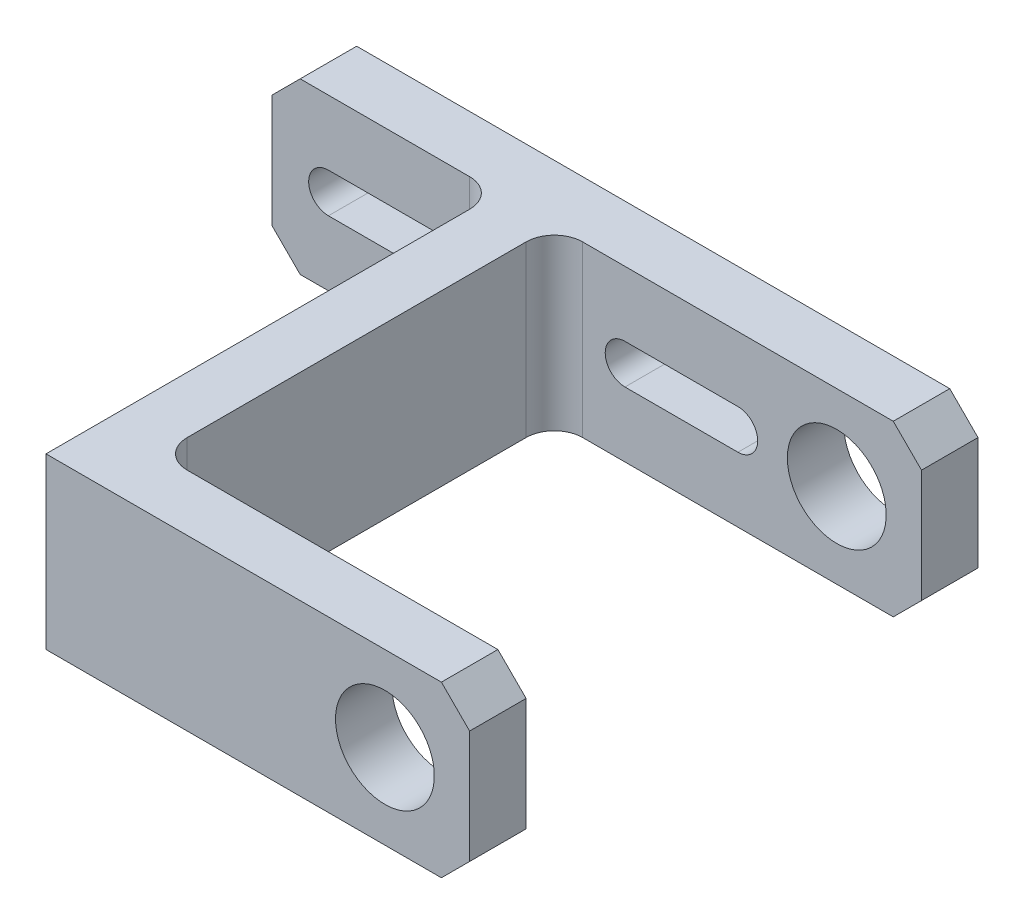
from build123d import *

# Parameters (mm, degrees)
BOSS_EXTRUDE1_DEPTH     = 30
SKETCH3_W               = 230
SKETCH3_H               = 60
SKETCH3_R               = 17.5
BOSS_EXTRUDE2_DEPTH     = 20
FILLET1_R               = 10
CHAMFER1_SIZE           = 10
SKETCH5_R               = 17.5
CUT_EXTRUDE1_DEPTH      = 1
CUT_EXTRUDE1_DEPTH_BACK = 181


with BuildPart() as part:
    # Sketch1 → Boss-Extrude1 (new body, symmetric)
    with BuildSketch(Plane(origin=(0, 0, 0), x_dir=(1, 0, 0), z_dir=(0, 1, 0))):
        Polygon((0, 160), (10, 160), (20, 160), (20, 20), (150, 20), (150, 0), (0, 0), align=None)
    extrude(amount=BOSS_EXTRUDE1_DEPTH, both=True)

    # Sketch3 → Boss-Extrude2 (add)
    with BuildSketch(Plane(origin=(0, 0, -160), x_dir=(-1, 0, 0), z_dir=(0, 0, -1))):
        with Locations((-35, 0)):
            Rectangle(SKETCH3_W, SKETCH3_H)
        with Locations((-120, 0)):
            Circle(SKETCH3_R, mode=Mode.SUBTRACT)
        with BuildLine():
            Line((60, -7), (20, -7))
            ThreePointArc((20, -7), (13, 0), (20, 7))
            Line((20, 7), (60, 7))
            ThreePointArc((60, 7), (67, 0), (60, -7))
        make_face(mode=Mode.SUBTRACT)
        with BuildLine():
            Line((-45, -7), (-85, -7))
            ThreePointArc((-85, -7), (-92, 0), (-85, 7))
            Line((-85, 7), (-45, 7))
            ThreePointArc((-45, 7), (-38, 0), (-45, -7))
        make_face(mode=Mode.SUBTRACT)
    extrude(amount=BOSS_EXTRUDE2_DEPTH)

    # Fillet1
    fillet1_edges = [part.edges().sort_by_distance(p)[0] for p in [
        (20, 0, -160),
        (20, 0, -20),
        (0, 0, -160),
    ]]
    fillet(fillet1_edges, radius=FILLET1_R)

    # Chamfer1
    chamfer1_edges = [part.edges().sort_by_distance(p)[0] for p in [
        (150, 30, -10),
        (150, 30, -170),
        (150, -30, -170),
        (-80, -30, -170),
        (-80, 30, -170),
        (150, -30, -10),
    ]]
    chamfer(chamfer1_edges, length=CHAMFER1_SIZE)

    # Sketch5 → Cut-Extrude1 (cut, two sides)
    with BuildSketch(Plane(origin=(0, 0, -180), x_dir=(-1, 0, 0), z_dir=(0, 0, -1))) as cut_extrude1_sk:
        with Locations((-120, 0)):
            Circle(SKETCH5_R)
    extrude(amount=CUT_EXTRUDE1_DEPTH, mode=Mode.SUBTRACT)
    extrude(cut_extrude1_sk.sketch, amount=-CUT_EXTRUDE1_DEPTH_BACK, mode=Mode.SUBTRACT)


solid = part.part
